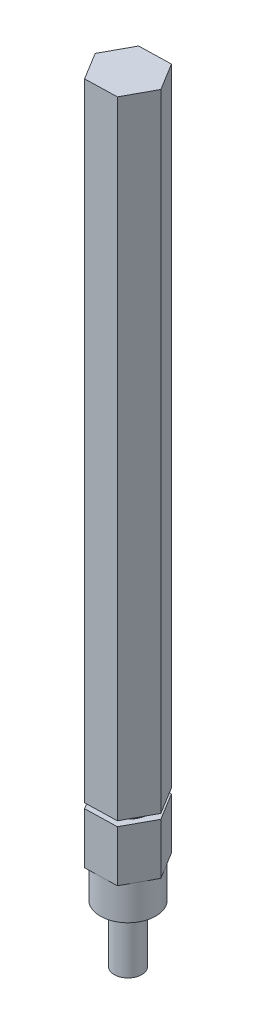
from build123d import *

# Parameters (mm, degrees)
SKETCH1_R           = 3.1496
BOSS_EXTRUDE1_DEPTH = 13.208
SKETCH2_R           = 6.35
BOSS_EXTRUDE2_DEPTH = 7.8867
BOSS_EXTRUDE3_DEPTH = 11.7094
SKETCH4_R           = 5.0292
BOSS_EXTRUDE4_DEPTH = 1.1684
BOSS_EXTRUDE5_DEPTH = 143.51


with BuildPart() as part:
    # Sketch1 → Boss-Extrude1 (new body)
    with BuildSketch(Plane(origin=(0, 0, 0), x_dir=(1, 0, 0), z_dir=(0, 1, 0))):
        Circle(SKETCH1_R)
    extrude(amount=BOSS_EXTRUDE1_DEPTH)

    # Sketch2 → Boss-Extrude2 (add)
    with BuildSketch(Plane(origin=(0, 13.208, 0), x_dir=(1, 0, 0), z_dir=(0, 1, 0))):
        Circle(SKETCH2_R)
    extrude(amount=BOSS_EXTRUDE2_DEPTH)

    # Sketch3 → Boss-Extrude3 (add)
    with BuildSketch(Plane(origin=(0, 21.0947, 0), x_dir=(1, 0, 0), z_dir=(0, 1, 0))):
        Polygon((3.828614027, -6.253402911), (7.329912794, 0.188975553), (3.501298767, 6.442378464), (-3.828614027, 6.253402911), (-7.329912794, -0.188975553), (-3.501298767, -6.442378464), align=None)
    extrude(amount=BOSS_EXTRUDE3_DEPTH)

    # Sketch4 → Boss-Extrude4 (add)
    with BuildSketch(Plane(origin=(0, 32.8041, 0), x_dir=(1, 0, 0), z_dir=(0, 1, 0))):
        Circle(SKETCH4_R)
    extrude(amount=BOSS_EXTRUDE4_DEPTH)

    # Sketch5 → Boss-Extrude5 (add)
    with BuildSketch(Plane(origin=(0, 33.9725, 0), x_dir=(1, 0, 0), z_dir=(0, 1, 0))):
        Polygon((-3.828614027, 6.253402911), (-7.329912794, -0.188975553), (-3.501298767, -6.442378464), (3.828614027, -6.253402911), (7.329912794, 0.188975553), (3.501298767, 6.442378464), align=None)
    extrude(amount=BOSS_EXTRUDE5_DEPTH)


solid = part.part
